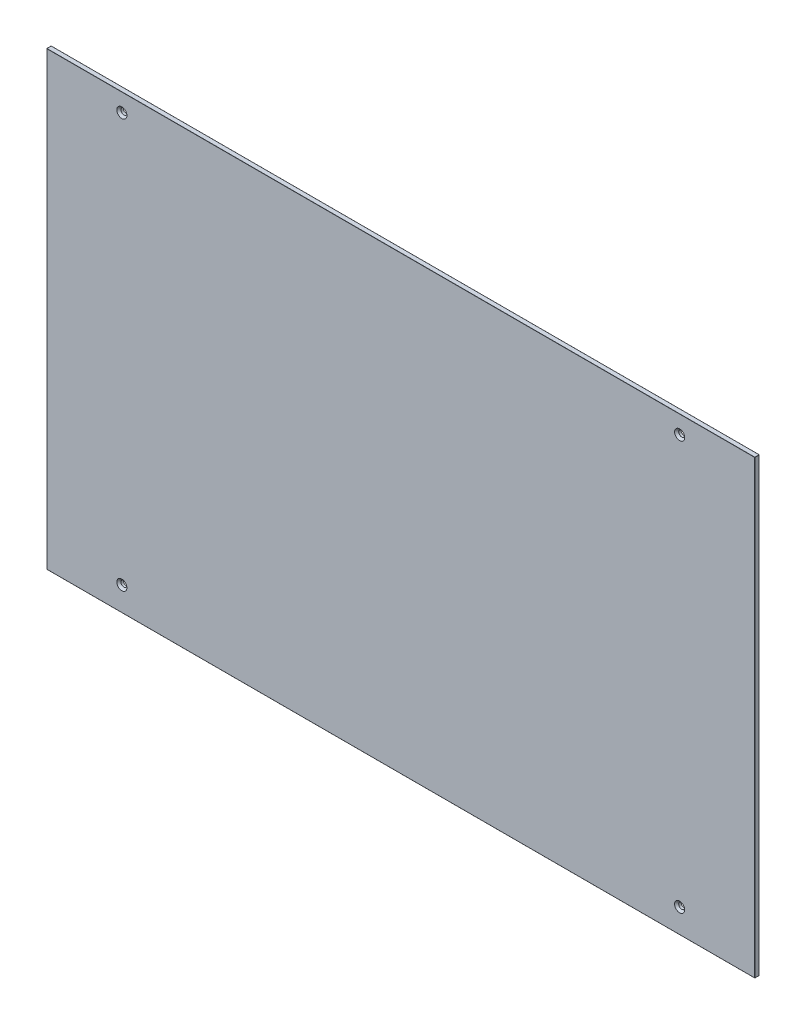
from build123d import *

# Parameters (mm, degrees)
SKETCH1_W           = 942
SKETCH1_H           = 600
BOSS_EXTRUDE1_DEPTH = 6
SKETCH2_R           = 4
CUT_EXTRUDE1_DEPTH  = 7
CHAMFER1_SIZE       = 2.75
FILLET1_R           = 0.2


with BuildPart() as part:
    # Sketch1 → Boss-Extrude1 (new body)
    with BuildSketch(Plane.XY):
        Rectangle(SKETCH1_W, SKETCH1_H)
    extrude(amount=BOSS_EXTRUDE1_DEPTH)

    # Sketch2 → Cut-Extrude1 (cut, through all)
    with BuildSketch(Plane.XY.offset(6)):
        with Locations((-371, 276)):
            Circle(SKETCH2_R)
        with Locations((371, 276)):
            Circle(SKETCH2_R)
        with Locations((371, -268)):
            Circle(SKETCH2_R)
        with Locations((-371, -268)):
            Circle(SKETCH2_R)
    extrude(amount=-CUT_EXTRUDE1_DEPTH, mode=Mode.SUBTRACT)

    # Chamfer1
    chamfer1_edges = [part.edges().sort_by_distance(p)[0] for p in [
        (-375, 276, 6),
        (367, 276, 6),
        (367, -268, 6),
        (-375, -268, 6),
    ]]
    chamfer(chamfer1_edges, length=CHAMFER1_SIZE)

    # Fillet1
    fillet1_edges = [part.edges().sort_by_distance(p)[0] for p in [
        (-471, 0, 6),
        (0, -300, 6),
        (471, 0, 6),
        (0, -300, 0),
        (-471, 0, 0),
        (0, 300, 0),
        (471, 0, 0),
        (0, 300, 6),
        (471, -300, 3),
        (-471, -300, 3),
        (-471, 300, 3),
        (471, 300, 3),
    ]]
    fillet(fillet1_edges, radius=FILLET1_R)


solid = part.part
